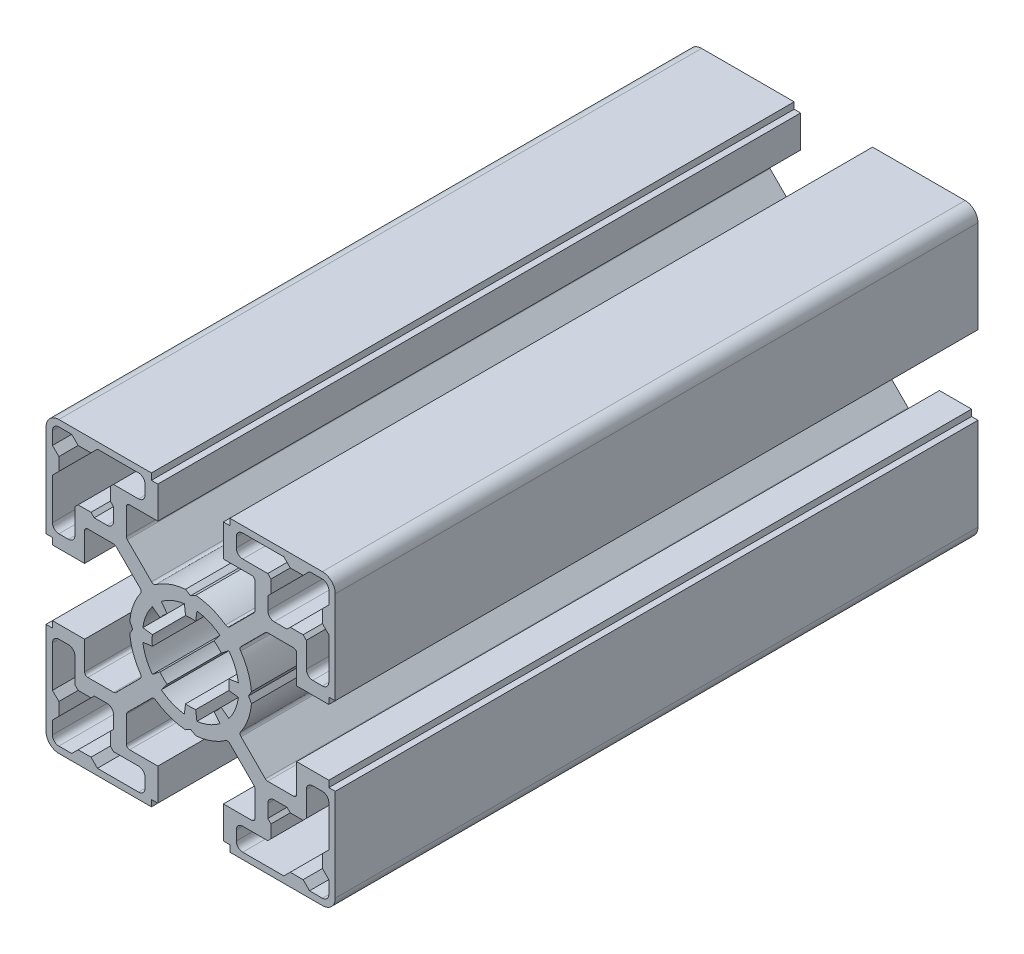
from build123d import *

# Parameters (mm, degrees)
AUFSATZ_LINEAR_AUSTRAGEN1_DEPTH = 100


with BuildPart() as part:
    # Skizze1 → Aufsatz-Linear austragen1 (new body)
    with BuildSketch(Plane.XY):
        with BuildLine():
            Line((15.9288033, -2.360241658), (16.394498423, -3.166849271))
            ThreePointArc((16.394498423, -3.166849271), (15.861767217, -5.593221036), (14.718220973, -7.798529283))
            ThreePointArc((14.718220973, -7.798529283), (14.630123006, -8.128674714), (14.774636934, -8.438308339))
            Line((14.774636934, -8.438308339), (18.550123643, -12.213795048))
            ThreePointArc((18.550123643, -12.213795048), (18.712335318, -12.322181423), (18.903677034, -12.360241657))
            Line((18.903677034, -12.360241657), (22.9288033, -12.360241657))
            ThreePointArc((22.9288033, -12.360241657), (23.28235669, -12.213795048), (23.4288033, -11.860241657))
            Line((23.4288033, -11.860241657), (23.4288033, -7.460241657))
            Line((23.4288033, -7.460241657), (28.4288033, -7.460241657))
            Line((28.4288033, -7.460241657), (28.4288033, -8.460241657))
            Line((28.4288033, -8.460241657), (29.4288033, -8.460241657))
            Line((29.4288033, -8.460241657), (29.4288033, -22.860241657))
            ThreePointArc((29.4288033, -22.860241657), (28.843016862, -24.27445522), (27.4288033, -24.860241657))
            Line((27.4288033, -24.860241657), (13.0288033, -24.860241657))
            Line((13.0288033, -24.860241657), (13.0288033, -23.860241657))
            Line((13.0288033, -23.860241657), (12.0288033, -23.860241657))
            Line((12.0288033, -23.860241657), (12.0288033, -18.860241657))
            Line((12.0288033, -18.860241657), (16.4288033, -18.860241657))
            ThreePointArc((16.4288033, -18.860241657), (16.78235669, -18.713795048), (16.9288033, -18.360241657))
            Line((16.9288033, -18.360241657), (16.9288033, -14.335115391))
            ThreePointArc((16.9288033, -14.335115391), (16.890743066, -14.143773675), (16.78235669, -13.981562001))
            Line((16.78235669, -13.981562001), (13.006869981, -10.206075292))
            ThreePointArc((13.006869981, -10.206075292), (12.697236356, -10.061561363), (12.367090926, -10.149659331))
            ThreePointArc((12.367090926, -10.149659331), (10.161782678, -11.293205574), (7.735410913, -11.82593678))
            Line((7.735410913, -11.82593678), (6.9288033, -11.360241657))
            Line((6.9288033, -11.360241657), (6.122195686, -11.82593678))
            ThreePointArc((6.122195686, -11.82593678), (3.695823921, -11.293205574), (1.490515673, -10.149659331))
            ThreePointArc((1.490515673, -10.149659331), (1.160370243, -10.061561363), (0.850736618, -10.206075291))
            Line((0.850736618, -10.206075291), (-2.924750091, -13.981562001))
            ThreePointArc((-2.924750091, -13.981562001), (-3.033136467, -14.143773675), (-3.0711967, -14.335115391))
            Line((-3.0711967, -14.335115391), (-3.0711967, -18.360241657))
            ThreePointArc((-3.0711967, -18.360241657), (-2.924750091, -18.713795048), (-2.5711967, -18.860241657))
            Line((-2.5711967, -18.860241657), (1.8288033, -18.860241657))
            Line((1.8288033, -18.860241657), (1.8288033, -23.860241657))
            Line((1.8288033, -23.860241657), (0.8288033, -23.860241657))
            Line((0.8288033, -23.860241657), (0.8288033, -24.860241657))
            Line((0.8288033, -24.860241657), (-13.5711967, -24.860241657))
            ThreePointArc((-13.5711967, -24.860241657), (-14.985410263, -24.27445522), (-15.571196701, -22.860241657))
            Line((-15.571196701, -22.860241657), (-15.571196701, -8.460241657))
            Line((-15.571196701, -8.460241657), (-14.571196701, -8.460241657))
            Line((-14.571196701, -8.460241657), (-14.571196701, -7.460241657))
            Line((-14.571196701, -7.460241657), (-9.5711967, -7.460241657))
            Line((-9.5711967, -7.460241657), (-9.5711967, -11.860241657))
            ThreePointArc((-9.5711967, -11.860241657), (-9.424750091, -12.213795048), (-9.0711967, -12.360241657))
            Line((-9.0711967, -12.360241657), (-5.046070434, -12.360241657))
            ThreePointArc((-5.046070434, -12.360241657), (-4.854728718, -12.322181423), (-4.692517044, -12.213795048))
            Line((-4.692517044, -12.213795048), (-0.917030335, -8.438308339))
            ThreePointArc((-0.917030335, -8.438308339), (-0.772516406, -8.128674714), (-0.860614374, -7.798529283))
            ThreePointArc((-0.860614374, -7.798529283), (-2.004160617, -5.593221036), (-2.536891823, -3.166849271))
            Line((-2.536891823, -3.166849271), (-2.0711967, -2.360241658))
            Line((-2.0711967, -2.360241658), (-2.536891823, -1.553634044))
            ThreePointArc((-2.536891823, -1.553634044), (-2.004160617, 0.872737721), (-0.860614374, 3.078045969))
            ThreePointArc((-0.860614374, 3.078045969), (-0.772516406, 3.4081914), (-0.917030335, 3.717825024))
            Line((-0.917030335, 3.717825024), (-4.692517044, 7.493311734))
            ThreePointArc((-4.692517044, 7.493311734), (-4.854728718, 7.601698109), (-5.046070434, 7.639758343))
            Line((-5.046070434, 7.639758343), (-9.0711967, 7.639758343))
            ThreePointArc((-9.0711967, 7.639758343), (-9.424750091, 7.493311734), (-9.5711967, 7.139758343))
            Line((-9.5711967, 7.139758343), (-9.5711967, 2.739758343))
            Line((-9.5711967, 2.739758343), (-14.571196701, 2.739758343))
            Line((-14.571196701, 2.739758343), (-14.571196701, 3.739758343))
            Line((-14.571196701, 3.739758343), (-15.571196701, 3.739758343))
            Line((-15.571196701, 3.739758343), (-15.571196701, 18.139758343))
            ThreePointArc((-15.571196701, 18.139758343), (-14.985410263, 19.553971906), (-13.571196701, 20.139758343))
            Line((-13.571196701, 20.139758343), (0.8288033, 20.139758343))
            Line((0.8288033, 20.139758343), (0.8288033, 19.139758343))
            Line((0.8288033, 19.139758343), (1.8288033, 19.139758343))
            Line((1.8288033, 19.139758343), (1.8288033, 14.139758343))
            Line((1.8288033, 14.139758343), (-2.5711967, 14.139758343))
            ThreePointArc((-2.5711967, 14.139758343), (-2.924750091, 13.993311734), (-3.0711967, 13.639758343))
            Line((-3.0711967, 13.639758343), (-3.0711967, 9.614632077))
            ThreePointArc((-3.0711967, 9.614632077), (-3.033136466, 9.423290361), (-2.924750091, 9.261078687))
            Line((-2.924750091, 9.261078687), (0.850736618, 5.485591977))
            ThreePointArc((0.850736618, 5.485591977), (1.160370243, 5.341078049), (1.490515673, 5.429176017))
            ThreePointArc((1.490515673, 5.429176017), (3.695823921, 6.57272226), (6.122195686, 7.105453466))
            Line((6.122195686, 7.105453466), (6.9288033, 6.639758343))
            Line((6.9288033, 6.639758343), (7.735410913, 7.105453466))
            ThreePointArc((7.735410913, 7.105453466), (10.161782678, 6.57272226), (12.367090926, 5.429176017))
            ThreePointArc((12.367090926, 5.429176017), (12.697236357, 5.341078049), (13.006869981, 5.485591977))
            Line((13.006869981, 5.485591977), (16.78235669, 9.261078687))
            ThreePointArc((16.78235669, 9.261078687), (16.890743066, 9.423290361), (16.9288033, 9.614632077))
            Line((16.9288033, 9.614632077), (16.9288033, 13.639758343))
            ThreePointArc((16.9288033, 13.639758343), (16.78235669, 13.993311734), (16.4288033, 14.139758343))
            Line((16.4288033, 14.139758343), (12.0288033, 14.139758343))
            Line((12.0288033, 14.139758343), (12.0288033, 19.139758343))
            Line((12.0288033, 19.139758343), (13.0288033, 19.139758343))
            Line((13.0288033, 19.139758343), (13.0288033, 20.139758343))
            Line((13.0288033, 20.139758343), (27.4288033, 20.139758343))
            ThreePointArc((27.4288033, 20.139758343), (28.843016863, 19.553971906), (29.4288033, 18.139758343))
            Line((29.4288033, 18.139758343), (29.4288033, 3.739758343))
            Line((29.4288033, 3.739758343), (28.4288033, 3.739758343))
            Line((28.4288033, 3.739758343), (28.4288033, 2.739758343))
            Line((28.4288033, 2.739758343), (23.4288033, 2.739758343))
            Line((23.4288033, 2.739758343), (23.4288033, 7.139758343))
            ThreePointArc((23.4288033, 7.139758343), (23.28235669, 7.493311734), (22.9288033, 7.639758343))
            Line((22.9288033, 7.639758343), (18.903677034, 7.639758343))
            ThreePointArc((18.903677034, 7.639758343), (18.712335317, 7.601698109), (18.550123643, 7.493311734))
            Line((18.550123643, 7.493311734), (14.774636934, 3.717825024))
            ThreePointArc((14.774636934, 3.717825024), (14.630123006, 3.4081914), (14.718220973, 3.078045969))
            ThreePointArc((14.718220973, 3.078045969), (15.861767217, 0.872737721), (16.394498423, -1.553634044))
            Line((16.394498423, -1.553634044), (15.9288033, -2.360241658))
        make_face()
        with BuildLine():
            Line((14.36463976, -3.339188099), (12.877472468, -3.14339881))
            ThreePointArc((12.877472468, -3.14339881), (12.9288033, -2.360241657), (12.877472468, -1.577084504))
            Line((12.877472468, -1.577084504), (14.36463976, -1.381295215))
            ThreePointArc((14.36463976, -1.381295215), (13.857899794, 0.509884086), (12.878953352, 2.205469061))
            Line((12.878953352, 2.205469061), (11.688923341, 1.292326917))
            ThreePointArc((11.688923341, 1.292326917), (11.171443987, 1.88239903), (10.581371874, 2.399878385))
            Line((10.581371874, 2.399878385), (11.494514017, 3.589908395))
            ThreePointArc((11.494514017, 3.589908395), (9.798929043, 4.568854837), (7.907749741, 5.075594803))
            Line((7.907749741, 5.075594803), (7.711960453, 3.588427511))
            ThreePointArc((7.711960453, 3.588427511), (6.9288033, 3.639758343), (6.145646146, 3.588427511))
            Line((6.145646146, 3.588427511), (5.949856858, 5.075594803))
            ThreePointArc((5.949856858, 5.075594803), (4.058677557, 4.568854837), (2.363092582, 3.589908395))
            Line((2.363092582, 3.589908395), (3.276234726, 2.399878385))
            ThreePointArc((3.276234726, 2.399878385), (2.686162613, 1.88239903), (2.168683258, 1.292326917))
            Line((2.168683258, 1.292326917), (0.978653247, 2.205469061))
            ThreePointArc((0.978653247, 2.205469061), (-0.000293194, 0.509884086), (-0.507033161, -1.381295215))
            Line((-0.507033161, -1.381295215), (0.980134132, -1.577084504))
            ThreePointArc((0.980134132, -1.577084504), (0.9288033, -2.360241657), (0.980134132, -3.14339881))
            Line((0.980134132, -3.14339881), (-0.507033161, -3.339188099))
            ThreePointArc((-0.507033161, -3.339188099), (-0.000293194, -5.2303674), (0.978653247, -6.925952375))
            Line((0.978653247, -6.925952375), (2.168683258, -6.012810231))
            ThreePointArc((2.168683258, -6.012810231), (2.686162613, -6.602882344), (3.276234726, -7.120361699))
            Line((3.276234726, -7.120361699), (2.363092582, -8.310391709))
            ThreePointArc((2.363092582, -8.310391709), (4.058677557, -9.289338151), (5.949856858, -9.796078118))
            Line((5.949856858, -9.796078118), (6.145646146, -8.308910825))
            ThreePointArc((6.145646146, -8.308910825), (6.9288033, -8.360241657), (7.711960453, -8.308910825))
            Line((7.711960453, -8.308910825), (7.907749741, -9.796078118))
            ThreePointArc((7.907749741, -9.796078118), (9.798929043, -9.289338151), (11.494514017, -8.310391709))
            Line((11.494514017, -8.310391709), (10.581371874, -7.120361699))
            ThreePointArc((10.581371874, -7.120361699), (11.171443987, -6.602882344), (11.688923341, -6.012810231))
            Line((11.688923341, -6.012810231), (12.878953352, -6.925952375))
            ThreePointArc((12.878953352, -6.925952375), (13.857899794, -5.2303674), (14.36463976, -3.339188099))
        make_face(mode=Mode.SUBTRACT)
        with BuildLine():
            Line((-5.071196701, 15.639758343), (-1.171196701, 15.639758343))
            ThreePointArc((-1.171196701, 15.639758343), (-0.46408992, 15.932651562), (-0.171196701, 16.639758343))
            Line((-0.171196701, 16.639758343), (-0.171196701, 18.139758343))
            ThreePointArc((-0.171196701, 18.139758343), (-0.46408992, 18.846865124), (-1.171196701, 19.139758343))
            Line((-1.171196701, 19.139758343), (-7.5711967, 19.139758343))
            Line((-7.5711967, 19.139758343), (-8.5711967, 18.139758343))
            Line((-8.5711967, 18.139758343), (-10.5711967, 18.139758343))
            Line((-10.5711967, 18.139758343), (-11.571196701, 19.139758343))
            Line((-11.571196701, 19.139758343), (-13.571196701, 19.139758343))
            ThreePointArc((-13.571196701, 19.139758343), (-14.278303482, 18.846865124), (-14.571196701, 18.139758343))
            Line((-14.571196701, 18.139758343), (-14.571196701, 16.139758343))
            Line((-14.571196701, 16.139758343), (-13.5711967, 15.139758343))
            Line((-13.5711967, 15.139758343), (-13.5711967, 13.139758343))
            Line((-13.5711967, 13.139758343), (-14.571196701, 12.139758343))
            Line((-14.571196701, 12.139758343), (-14.571196701, 5.739758343))
            ThreePointArc((-14.571196701, 5.739758343), (-14.278303482, 5.032651562), (-13.571196701, 4.739758343))
            Line((-13.571196701, 4.739758343), (-12.071196701, 4.739758343))
            ThreePointArc((-12.071196701, 4.739758343), (-11.364089919, 5.032651562), (-11.071196701, 5.739758343))
            Line((-11.071196701, 5.739758343), (-11.071196701, 9.639758343))
            Line((-11.071196701, 9.639758343), (-10.5711967, 10.139758343))
            Line((-10.5711967, 10.139758343), (-8.571196701, 10.139758343))
            Line((-8.571196701, 10.139758343), (-8.0711967, 9.639758343))
            Line((-8.0711967, 9.639758343), (-6.071196701, 9.639758343))
            ThreePointArc((-6.071196701, 9.639758343), (-5.364089919, 9.932651562), (-5.071196701, 10.639758343))
            Line((-5.071196701, 10.639758343), (-5.071196701, 12.639758343))
            Line((-5.071196701, 12.639758343), (-5.571196701, 13.139758343))
            Line((-5.571196701, 13.139758343), (-5.571196701, 15.139758343))
            Line((-5.571196701, 15.139758343), (-5.071196701, 15.639758343))
        make_face(mode=Mode.SUBTRACT)
        with BuildLine():
            Line((25.9288033, 4.739758343), (27.4288033, 4.739758343))
            ThreePointArc((27.4288033, 4.739758343), (28.135910081, 5.032651562), (28.4288033, 5.739758343))
            Line((28.4288033, 5.739758343), (28.4288033, 12.139758343))
            Line((28.4288033, 12.139758343), (27.4288033, 13.139758343))
            Line((27.4288033, 13.139758343), (27.4288033, 15.139758343))
            Line((27.4288033, 15.139758343), (28.4288033, 16.139758343))
            Line((28.4288033, 16.139758343), (28.4288033, 18.139758343))
            ThreePointArc((28.4288033, 18.139758343), (28.135910081, 18.846865124), (27.4288033, 19.139758343))
            Line((27.4288033, 19.139758343), (25.4288033, 19.139758343))
            Line((25.4288033, 19.139758343), (24.4288033, 18.139758343))
            Line((24.4288033, 18.139758343), (22.4288033, 18.139758343))
            Line((22.4288033, 18.139758343), (21.4288033, 19.139758343))
            Line((21.4288033, 19.139758343), (15.028803301, 19.139758343))
            ThreePointArc((15.028803301, 19.139758343), (14.321696519, 18.846865124), (14.028803301, 18.139758343))
            Line((14.028803301, 18.139758343), (14.028803301, 16.639758343))
            ThreePointArc((14.028803301, 16.639758343), (14.321696519, 15.932651562), (15.028803301, 15.639758343))
            Line((15.028803301, 15.639758343), (18.9288033, 15.639758343))
            Line((18.9288033, 15.639758343), (19.4288033, 15.139758343))
            Line((19.4288033, 15.139758343), (19.4288033, 13.139758343))
            Line((19.4288033, 13.139758343), (18.9288033, 12.639758343))
            Line((18.9288033, 12.639758343), (18.9288033, 10.639758343))
            ThreePointArc((18.9288033, 10.639758343), (19.221696519, 9.932651562), (19.9288033, 9.639758343))
            Line((19.9288033, 9.639758343), (21.9288033, 9.639758343))
            Line((21.9288033, 9.639758343), (22.4288033, 10.139758343))
            Line((22.4288033, 10.139758343), (24.4288033, 10.139758343))
            Line((24.4288033, 10.139758343), (24.9288033, 9.639758343))
            Line((24.9288033, 9.639758343), (24.9288033, 5.739758343))
            ThreePointArc((24.9288033, 5.739758343), (25.221696519, 5.032651562), (25.9288033, 4.739758343))
        make_face(mode=Mode.SUBTRACT)
        with BuildLine():
            Line((-12.0711967, -9.460241658), (-13.5711967, -9.460241658))
            ThreePointArc((-13.5711967, -9.460241658), (-14.278303482, -9.753134876), (-14.5711967, -10.460241658))
            Line((-14.5711967, -10.460241658), (-14.5711967, -16.860241657))
            Line((-14.5711967, -16.860241657), (-13.5711967, -17.860241657))
            Line((-13.5711967, -17.860241657), (-13.5711967, -19.860241657))
            Line((-13.5711967, -19.860241657), (-14.5711967, -20.860241657))
            Line((-14.5711967, -20.860241657), (-14.5711967, -22.860241657))
            ThreePointArc((-14.5711967, -22.860241657), (-14.278303482, -23.567348438), (-13.5711967, -23.860241657))
            Line((-13.5711967, -23.860241657), (-11.5711967, -23.860241657))
            Line((-11.5711967, -23.860241657), (-10.5711967, -22.860241657))
            Line((-10.5711967, -22.860241657), (-8.5711967, -22.860241657))
            Line((-8.5711967, -22.860241657), (-7.5711967, -23.860241657))
            Line((-7.5711967, -23.860241657), (-1.171196701, -23.860241657))
            ThreePointArc((-1.171196701, -23.860241657), (-0.46408992, -23.567348438), (-0.171196701, -22.860241657))
            Line((-0.171196701, -22.860241657), (-0.171196701, -21.360241658))
            ThreePointArc((-0.171196701, -21.360241658), (-0.46408992, -20.653134876), (-1.171196701, -20.360241658))
            Line((-1.171196701, -20.360241658), (-5.0711967, -20.360241658))
            Line((-5.0711967, -20.360241658), (-5.571196701, -19.860241657))
            Line((-5.571196701, -19.860241657), (-5.571196701, -17.860241657))
            Line((-5.571196701, -17.860241657), (-5.0711967, -17.360241657))
            Line((-5.0711967, -17.360241657), (-5.0711967, -15.360241657))
            ThreePointArc((-5.0711967, -15.360241657), (-5.364089919, -14.653134876), (-6.0711967, -14.360241657))
            Line((-6.0711967, -14.360241657), (-8.0711967, -14.360241657))
            Line((-8.0711967, -14.360241657), (-8.5711967, -14.860241657))
            Line((-8.5711967, -14.860241657), (-10.5711967, -14.860241657))
            Line((-10.5711967, -14.860241657), (-11.0711967, -14.360241657))
            Line((-11.0711967, -14.360241657), (-11.0711967, -10.460241658))
            ThreePointArc((-11.0711967, -10.460241658), (-11.364089919, -9.753134876), (-12.0711967, -9.460241658))
        make_face(mode=Mode.SUBTRACT)
        with BuildLine():
            Line((28.4288033, -16.860241657), (28.4288033, -10.460241657))
            ThreePointArc((28.4288033, -10.460241657), (28.135910081, -9.753134876), (27.4288033, -9.460241657))
            Line((27.4288033, -9.460241657), (25.9288033, -9.460241657))
            ThreePointArc((25.9288033, -9.460241657), (25.221696519, -9.753134876), (24.9288033, -10.460241657))
            Line((24.9288033, -10.460241657), (24.9288033, -14.360241657))
            Line((24.9288033, -14.360241657), (24.4288033, -14.860241657))
            Line((24.4288033, -14.860241657), (22.4288033, -14.860241657))
            Line((22.4288033, -14.860241657), (21.9288033, -14.360241657))
            Line((21.9288033, -14.360241657), (19.9288033, -14.360241657))
            ThreePointArc((19.9288033, -14.360241657), (19.221696519, -14.653134876), (18.9288033, -15.360241657))
            Line((18.9288033, -15.360241657), (18.9288033, -17.360241657))
            Line((18.9288033, -17.360241657), (19.4288033, -17.860241657))
            Line((19.4288033, -17.860241657), (19.4288033, -19.860241657))
            Line((19.4288033, -19.860241657), (18.9288033, -20.360241658))
            Line((18.9288033, -20.360241658), (15.028803301, -20.360241658))
            ThreePointArc((15.028803301, -20.360241658), (14.321696519, -20.653134876), (14.028803301, -21.360241658))
            Line((14.028803301, -21.360241658), (14.028803301, -22.860241657))
            ThreePointArc((14.028803301, -22.860241657), (14.321696519, -23.567348438), (15.028803301, -23.860241657))
            Line((15.028803301, -23.860241657), (21.4288033, -23.860241657))
            Line((21.4288033, -23.860241657), (22.4288033, -22.860241657))
            Line((22.4288033, -22.860241657), (24.4288033, -22.860241657))
            Line((24.4288033, -22.860241657), (25.4288033, -23.860241657))
            Line((25.4288033, -23.860241657), (27.4288033, -23.860241657))
            ThreePointArc((27.4288033, -23.860241657), (28.135910081, -23.567348438), (28.4288033, -22.860241657))
            Line((28.4288033, -22.860241657), (28.4288033, -20.860241657))
            Line((28.4288033, -20.860241657), (27.4288033, -19.860241657))
            Line((27.4288033, -19.860241657), (27.4288033, -17.860241657))
            Line((27.4288033, -17.860241657), (28.4288033, -16.860241657))
        make_face(mode=Mode.SUBTRACT)
    extrude(amount=AUFSATZ_LINEAR_AUSTRAGEN1_DEPTH)


solid = part.part
